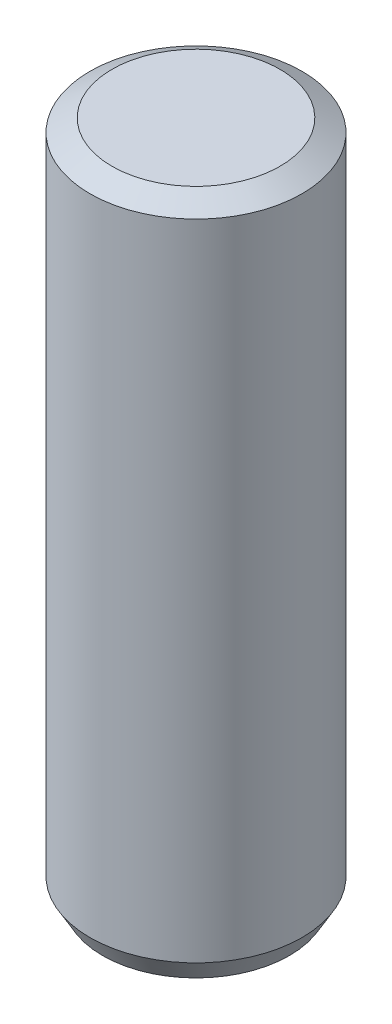
from build123d import *

# Parameters (mm, degrees)
SKETCH1_R             = 2.5
BOSS_EXTRUDE1_DEPTH   = 16
CHAMFER1_SIZE         = 0.3
CHAMFER1_SIZE2        = 0.519615242
CHAMFER1_PART_2_SIZE  = 0.3
CHAMFER1_PART_2_SIZE2 = 0.519615242


with BuildPart() as part:
    # Sketch1 → Boss-Extrude1 (new body)
    with BuildSketch(Plane(origin=(0, 0, 0), x_dir=(1, 0, 0), z_dir=(0, 1, 0))):
        Circle(SKETCH1_R)
    extrude(amount=BOSS_EXTRUDE1_DEPTH)

    # Chamfer1
    chamfer1_edges = [part.edges().sort_by_distance(p)[0] for p in [
        (-2.5, 0, 0),
    ]]
    chamfer1_side = [part.faces().sort_by_distance(p)[0] for p in [
        (0, 0, 0),
    ]]
    chamfer(chamfer1_edges, length=CHAMFER1_SIZE, length2=CHAMFER1_SIZE2, reference=chamfer1_side[0])

    # Chamfer1 part 2
    chamfer1_part_2_edges = [part.edges().sort_by_distance(p)[0] for p in [
        (-2.5, 16, 0),
    ]]
    chamfer1_part_2_side = [part.faces().sort_by_distance(p)[0] for p in [
        (-2.5, 8, 0),
    ]]
    chamfer(chamfer1_part_2_edges, length=CHAMFER1_PART_2_SIZE, length2=CHAMFER1_PART_2_SIZE2, reference=chamfer1_part_2_side[0])


solid = part.part
